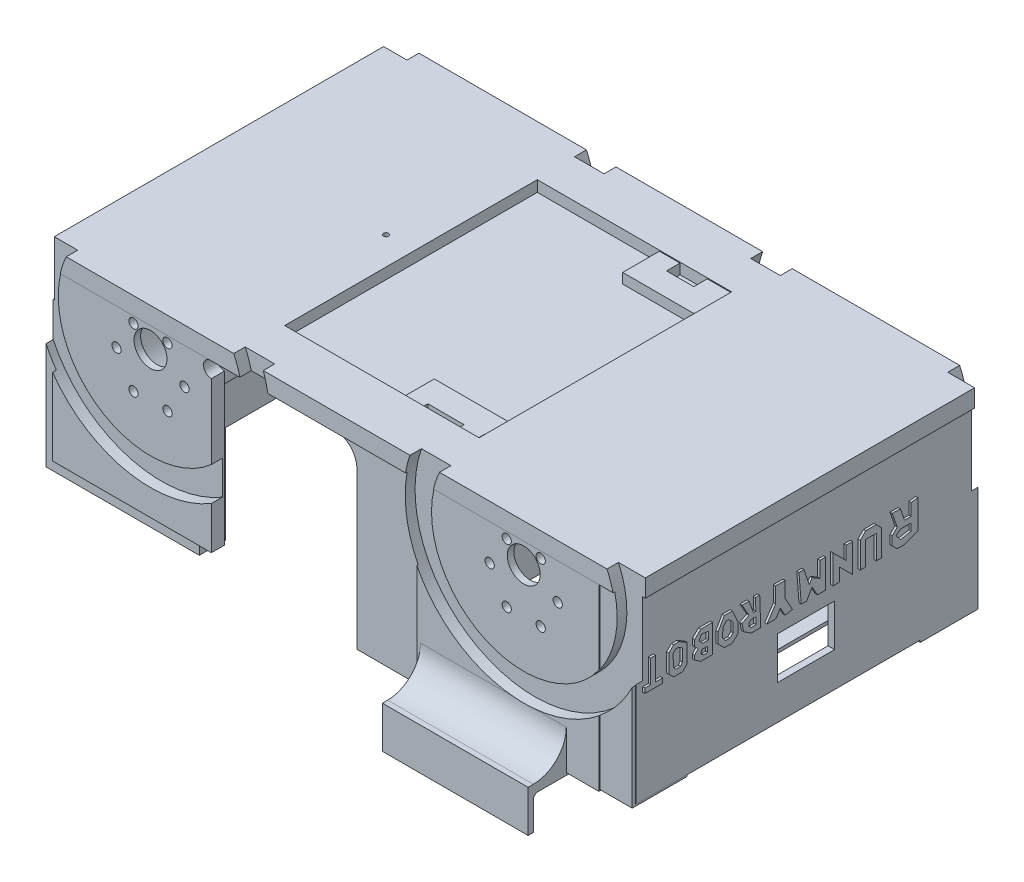
from build123d import *

# Parameters (mm, degrees)
MOTORHOLDERSSKETCH_R          = 23.41
MOTORHOLDERS_DEPTH            = 80
MOTORHOLDERS_DEPTH_BACK       = 80
MOTORHOLDERS_2_DEPTH          = 80
MOTORHOLDERS_2_DEPTH_BACK     = 80
SKETCH4_W                     = 262.774983374
SKETCH4_H                     = 153.112553215
CUT_EXTRUDE1_DEPTH            = 26
SKETCH6_W                     = 74.414236541
SKETCH6_H                     = 13.420779118
SKETCH6_W_2                   = 20.810206851
SKETCH6_H_2                   = 2.021058642
POWERBANKHOLDERS_DEPTH        = 30
POWERBANKHOLDERS_DEPTH_BACK   = 59
SKETCH6_W_3                   = 69.833389767
SKETCH6_H_3                   = 38.261259506
SKETCH6_W_4                   = 10.842850571
SKETCH6_H_4                   = 10.347679347
POWERBANKHOLDERS_2_DEPTH      = 30
POWERBANKHOLDERS_2_DEPTH_BACK = 59
SKETCH6_W_5                   = 55.674763771
SKETCH6_H_5                   = 37.111507406
SKETCH6_W_6                   = 12.844328805
SKETCH6_H_6                   = 18.336479725
SKETCH6_W_7                   = 12.407504742
SKETCH6_H_7                   = 16.443461188
POWERBANKHOLDERS_3_DEPTH      = 30
POWERBANKHOLDERS_3_DEPTH_BACK = 59
SKETCH6_W_8                   = 56.474336521
SKETCH6_H_8                   = 35.272094794
SKETCH6_W_9                   = 11.134493861
SKETCH6_H_9                   = 18.035399163
SKETCH6_W_10                  = 16.537391536
SKETCH6_H_10                  = 14.436538778
POWERBANKHOLDERS_4_DEPTH      = 30
POWERBANKHOLDERS_4_DEPTH_BACK = 59
SKETCH6_W_11                  = 28.150495439
SKETCH6_H_11                  = 24.933985152
SKETCH6_W_12                  = 10.177859407
SKETCH6_H_12                  = 9.83070569
POWERBANKHOLDERS_5_DEPTH      = 30
POWERBANKHOLDERS_5_DEPTH_BACK = 59
SKETCH6_W_13                  = 30.670744753
SKETCH6_H_13                  = 26.330219561
SKETCH6_W_14                  = 9.898416255
SKETCH6_H_14                  = 10.635603546
POWERBANKHOLDERS_6_DEPTH      = 30
POWERBANKHOLDERS_6_DEPTH_BACK = 59
SKETCH21_R                    = 156.395305675
SKETCH21_W                    = 88.537320887
SKETCH21_H                    = 115.069025425
BOTTOMPLATE_DEPTH             = 5
BOTTOMPLATE_DEPTH_BACK        = 3
SKETCH23_W                    = 72.331231332
SKETCH23_H                    = 81.163054316
SKETCH23_W_2                  = 82.936115801
SKETCH23_H_2                  = 87.063331284
MOTORMOUNTINGSUPPORT1_DEPTH   = 6
SKETCH24_W                    = 78.341994801
SKETCH24_H                    = 86.363062387
SKETCH24_W_2                  = 53.914675369
SKETCH24_H_2                  = 86.674739968
MOTORMOUNTINGSUPPOR2_DEPTH    = 6
SKETCH17_R                    = 2.1
SKETCH17_R_2                  = 7.5
MOTORHOLES1_DEPTH             = 31.5
SKETCH19_R                    = 2.1
SKETCH19_R_2                  = 7.5
CUT_EXTRUDE4_DEPTH            = 30
BOLTHOLESSKETCH3_R            = 2.1
BOLTHOLESSKETCH3_R_2          = 7.5
MOTORHOLES3_DEPTH             = 31.5
BOLTHOLESSKETCH4_R            = 2.1
BOLTHOLESSKETCH4_R_2          = 7.5
MOTORHOLES4_DEPTH             = 15
SKETCH29_W                    = 154.635205036
SKETCH29_H                    = 84.131588093
SKETCH29_W_2                  = 26
SKETCH29_H_2                  = 19.212652328
BOSS_EXTRUDE8_DEPTH           = 3
SKETCH27_W                    = 226.46009322
SKETCH27_H                    = 129.985211715
BOSS_EXTRUDE6_DEPTH           = 3
SKETCH28_W                    = 66.387115975
SKETCH28_H                    = 194.116469537
CELLPHONEPLATE_DEPTH          = 1.5
CELLPHONEPLATE_DEPTH_BACK     = 2.5
SKETCH40_W                    = 33.841577611
SKETCH40_H                    = 31.531825246
BOSS_EXTRUDE11_DEPTH          = 40
FILLET2_R                     = 15
FILLET3_R                     = 15
POWERBANKCUT_DEPTH            = 44.404272
MOTORHOLDEREXTRUDESKETCH_R    = 20.415
MOTORHOLDERCUT_DEPTH          = 77
MOTORHOLDERCUT_DEPTH_BACK     = 77
LABEL_DEPTH                   = 1
SKETCH32_W                    = 420.045569038
SKETCH32_H                    = 425.046527557
SKETCH32_W_2                  = 269.205670794
SKETCH32_H_2                  = 160.645125556
BASEDEFININGCUT_DEPTH         = 20
BASEDEFININGCUT_DEPTH_BACK    = 20
SKETCH36_R                    = 7.790164171
CUT_EXTRUDE6_DEPTH            = 40
SKETCH37_W                    = 55.340133611
SKETCH37_H                    = 29.7708905
CUT_EXTRUDE7_DEPTH            = 36
SKETCH38_R                    = 1.145182774
CUT_EXTRUDE8_DEPTH            = 10
SKETCH41_R                    = 54.5
SKETCH41_R_2                  = 42
SPACEFORWHEEL1_DEPTH          = 10
SPACEFORWHEEL1_DEPTH_BACK     = 5
SKETCH42_R                    = 54.5
SKETCH42_R_2                  = 42
CUT_EXTRUDE10_DEPTH           = 10
CUT_EXTRUDE10_DEPTH_BACK      = 5
SKETCH43_R                    = 54.5
SKETCH43_R_2                  = 42
CUT_EXTRUDE11_DEPTH           = 10
CUT_EXTRUDE11_DEPTH_BACK      = 5
SKETCH44_R                    = 54.5
SKETCH44_R_2                  = 42
CUT_EXTRUDE12_DEPTH           = 10
CUT_EXTRUDE12_DEPTH_BACK      = 5
SKETCH45_W                    = 114.137539603
SKETCH45_H                    = 89.690999312
BOSS_EXTRUDE12_DEPTH          = 2
FILLET4_R                     = 15
FILLET5_R                     = 15
SKETCH47_W                    = 66.387115975
SKETCH47_H                    = 3.279012993
SKETCH47_H_2                  = 2.432330743
BOSS_EXTRUDE14_DEPTH          = 15
FILLET6_R                     = 2
FILLET7_R                     = 2
FILLET8_R                     = 10
FILLET9_R                     = 10
FILLET10_R                    = 10
SKETCH49_R                    = 3.583077442
CUT_EXTRUDE13_DEPTH           = 6


with BuildPart() as part:
    # MotorHoldersSketch → MotorHolders (new body, two sides)
    with BuildSketch(Plane.XY) as motorholders_sk:
        Circle(MOTORHOLDERSSKETCH_R)
    extrude(amount=MOTORHOLDERS_DEPTH)
    extrude(motorholders_sk.sketch, amount=-MOTORHOLDERS_DEPTH_BACK)


with BuildPart() as body_2:
    # MotorHoldersSketch → MotorHolders 2 (new body, two sides)
    with BuildSketch(Plane.XY) as motorholders_2_sk:
        with Locations((170, 0)):
            Circle(MOTORHOLDERSSKETCH_R)
    extrude(amount=MOTORHOLDERS_2_DEPTH)
    extrude(motorholders_2_sk.sketch, amount=-MOTORHOLDERS_2_DEPTH_BACK)


with BuildPart() as cut_extrude1_tool:
    # Sketch4 → Cut-Extrude1 (new body)
    with BuildSketch(Plane(origin=(0, 0, 0), x_dir=(1, 0, 0), z_dir=(0, 1, 0))):
        with Locations((89.893628689, 0.176832173)):
            Rectangle(SKETCH4_W, SKETCH4_H)
    extrude(amount=-CUT_EXTRUDE1_DEPTH)


with BuildPart() as part_1:
    add(part.part)

    # Cut-Extrude1: cut by cut_extrude1_tool
    add(cut_extrude1_tool.part, mode=Mode.SUBTRACT)


with BuildPart() as body_2_1:
    add(body_2.part)

    # Cut-Extrude1: cut by cut_extrude1_tool
    add(cut_extrude1_tool.part, mode=Mode.SUBTRACT)


with BuildPart() as body_3:
    # Sketch6 → PowerBankHolders (new body, two sides)
    with BuildSketch(Plane(origin=(170, -34.829272125, 0), x_dir=(-1, 0, 0), z_dir=(0, -1, 0))) as powerbankholders_sk:
        with Locations((182.378728269, 72.238602394)):
            Rectangle(SKETCH6_W, SKETCH6_H)
        with Locations((203.359863582, 72.025840015)):
            Rectangle(SKETCH6_W_2, SKETCH6_H_2, mode=Mode.SUBTRACT)
    extrude(amount=POWERBANKHOLDERS_DEPTH)
    extrude(powerbankholders_sk.sketch, amount=-POWERBANKHOLDERS_DEPTH_BACK)



with BuildPart() as body_4:
    # Sketch6 → PowerBankHolders 2 (new body, two sides)
    with BuildSketch(Plane(origin=(170, -34.829272125, 0), x_dir=(-1, 0, 0), z_dir=(0, -1, 0))) as powerbankholders_2_sk:
        with Locations((184.398032618, -59.151522269)):
            Rectangle(SKETCH6_W_3, SKETCH6_H_3)
        with Locations((206.519672379, -65.314281269)):
            Rectangle(SKETCH6_W_4, SKETCH6_H_4, mode=Mode.SUBTRACT)
    extrude(amount=POWERBANKHOLDERS_2_DEPTH)
    extrude(powerbankholders_2_sk.sketch, amount=-POWERBANKHOLDERS_2_DEPTH_BACK)


with BuildPart() as body_5:
    # Sketch6 → PowerBankHolders 3 (new body, two sides)
    with BuildSketch(Plane(origin=(170, -34.829272125, 0), x_dir=(-1, 0, 0), z_dir=(0, -1, 0))) as powerbankholders_3_sk:
        with Locations((47.827743092, 59.306920349)):
            Rectangle(SKETCH6_W_5, SKETCH6_H_5)
        with Locations((34.93306737, 60.00949088)):
            Rectangle(SKETCH6_W_6, SKETCH6_H_6, mode=Mode.SUBTRACT)
        with Locations((60.073413265, 59.541495334)):
            Rectangle(SKETCH6_W_7, SKETCH6_H_7, mode=Mode.SUBTRACT)
    extrude(amount=POWERBANKHOLDERS_3_DEPTH)
    extrude(powerbankholders_3_sk.sketch, amount=-POWERBANKHOLDERS_3_DEPTH_BACK)


with BuildPart() as body_6:
    # Sketch6 → PowerBankHolders 4 (new body, two sides)
    with BuildSketch(Plane(origin=(170, -34.829272125, 0), x_dir=(-1, 0, 0), z_dir=(0, -1, 0))) as powerbankholders_4_sk:
        with Locations((48.322417758, -61.807610384)):
            Rectangle(SKETCH6_W_8, SKETCH6_H_8)
        with Locations((37.73953158, -63.792391966)):
            Rectangle(SKETCH6_W_9, SKETCH6_H_9, mode=Mode.SUBTRACT)
        with Locations((59.979410768, -62.645522509)):
            Rectangle(SKETCH6_W_10, SKETCH6_H_10, mode=Mode.SUBTRACT)
    extrude(amount=POWERBANKHOLDERS_4_DEPTH)
    extrude(powerbankholders_4_sk.sketch, amount=-POWERBANKHOLDERS_4_DEPTH_BACK)


with BuildPart() as body_7:
    # Sketch6 → PowerBankHolders 5 (new body, two sides)
    with BuildSketch(Plane(origin=(170, -34.829272125, 0), x_dir=(-1, 0, 0), z_dir=(0, -1, 0))) as powerbankholders_5_sk:
        with Locations((-34.775388772, -66.976665205)):
            Rectangle(SKETCH6_W_11, SKETCH6_H_11)
        with Locations((-36.725173705, -67.894738702)):
            Rectangle(SKETCH6_W_12, SKETCH6_H_12, mode=Mode.SUBTRACT)
    extrude(amount=POWERBANKHOLDERS_5_DEPTH)
    extrude(powerbankholders_5_sk.sketch, amount=-POWERBANKHOLDERS_5_DEPTH_BACK)


with BuildPart() as body_8:
    # Sketch6 → PowerBankHolders 6 (new body, two sides)
    with BuildSketch(Plane(origin=(170, -34.829272125, 0), x_dir=(-1, 0, 0), z_dir=(0, -1, 0))) as powerbankholders_6_sk:
        with Locations((-33.722690809, 64.697564271)):
            Rectangle(SKETCH6_W_13, SKETCH6_H_13)
        with Locations((-36.585452129, 63.859928969)):
            Rectangle(SKETCH6_W_14, SKETCH6_H_14, mode=Mode.SUBTRACT)
    extrude(amount=POWERBANKHOLDERS_6_DEPTH)
    extrude(powerbankholders_6_sk.sketch, amount=-POWERBANKHOLDERS_6_DEPTH_BACK)


with BuildPart() as body_3_1:
    add(body_3.part)

    add(body_4.part)  # BottomPlate merges body 4

    add(body_2_1.part)  # BottomPlate merges body 2

    add(part_1.part)  # BottomPlate merges part

    add(body_5.part)  # BottomPlate merges body 5

    add(body_6.part)  # BottomPlate merges body 6
    # Sketch21 → BottomPlate (add, two sides)
    with BuildSketch(Plane(origin=(0, 19.575, 0), x_dir=(1, 0, 0), z_dir=(0, 1, 0))) as bottomplate_sk:
        with Locations((85, 0)):
            Circle(SKETCH21_R)
        with Locations((82.978570093, -0.057259585)):
            Rectangle(SKETCH21_W, SKETCH21_H, mode=Mode.SUBTRACT)
    extrude(amount=BOTTOMPLATE_DEPTH)
    extrude(bottomplate_sk.sketch, amount=-BOTTOMPLATE_DEPTH_BACK)


    add(body_7.part)  # MotorMountingSupport1 merges body 7
    # Sketch23 → MotorMountingSupport1 (add)
    with BuildSketch(Plane.XY.offset(80)):
        with Locations((-8.424510745, -18.741332274)):
            Rectangle(SKETCH23_W, SKETCH23_H)
        with Locations((162.789906406, -21.691470758)):
            Rectangle(SKETCH23_W_2, SKETCH23_H_2)
    extrude(amount=-MOTORMOUNTINGSUPPORT1_DEPTH)


    add(body_8.part)  # MotorMountingSuppor2 merges body 8
    # Sketch24 → MotorMountingSuppor2 (add)
    with BuildSketch(Plane(origin=(0, 0, -80), x_dir=(-1, 0, 0), z_dir=(0, 0, -1))):
        with Locations((-163.019522912, -23.94412431)):
            Rectangle(SKETCH24_W, SKETCH24_H)
        with Locations((2.593149567, -20.814772641)):
            Rectangle(SKETCH24_W_2, SKETCH24_H_2)
    extrude(amount=-MOTORMOUNTINGSUPPOR2_DEPTH)

    # Sketch17 → MotorHoles1 (cut)
    with BuildSketch(Plane.XY.offset(80)):
        with Locations((185.5, 0)):
            Circle(SKETCH17_R)
        with Locations((177.75, -13.42)):
            Circle(SKETCH17_R)
        with Locations((162.25, -13.42)):
            Circle(SKETCH17_R)
        with Locations((154.5, 0)):
            Circle(SKETCH17_R)
        with Locations((162.25, 13.42)):
            Circle(SKETCH17_R)
        with Locations((177.75, 13.42)):
            Circle(SKETCH17_R)
        with Locations((170, 7)):
            Circle(SKETCH17_R_2)
    extrude(amount=-MOTORHOLES1_DEPTH, mode=Mode.SUBTRACT)

    # Sketch19 → Cut-Extrude4 (cut)
    with BuildSketch(Plane(origin=(0, 0, -80), x_dir=(-1, 0, 0), z_dir=(0, 0, -1))):
        with Locations((-185.5, 0)):
            Circle(SKETCH19_R)
        with Locations((-177.75, -13.42)):
            Circle(SKETCH19_R)
        with Locations((-162.25, -13.42)):
            Circle(SKETCH19_R)
        with Locations((-154.5, 0)):
            Circle(SKETCH19_R)
        with Locations((-162.25, 13.42)):
            Circle(SKETCH19_R)
        with Locations((-177.75, 13.42)):
            Circle(SKETCH19_R)
        with Locations((-170, 7)):
            Circle(SKETCH19_R_2)
    extrude(amount=-CUT_EXTRUDE4_DEPTH, mode=Mode.SUBTRACT)

    # BoltHolesSketch3 → MotorHoles3 (cut)
    with BuildSketch(Plane.XY.offset(80)):
        with Locations((7.75, -13.42)):
            Circle(BOLTHOLESSKETCH3_R)
        with Locations((15.5, 0)):
            Circle(BOLTHOLESSKETCH3_R)
        with Locations((7.75, 13.42)):
            Circle(BOLTHOLESSKETCH3_R)
        with Locations((-7.75, 13.42)):
            Circle(BOLTHOLESSKETCH3_R)
        with Locations((-15.5, 0)):
            Circle(BOLTHOLESSKETCH3_R)
        with Locations((-7.75, -13.42)):
            Circle(BOLTHOLESSKETCH3_R)
        with Locations((0, 7)):
            Circle(BOLTHOLESSKETCH3_R_2)
    extrude(amount=-MOTORHOLES3_DEPTH, mode=Mode.SUBTRACT)

    # BoltHolesSketch4 → MotorHoles4 (cut)
    with BuildSketch(Plane(origin=(0, 0, -80), x_dir=(-1, 0, 0), z_dir=(0, 0, -1))):
        with Locations((-15.5, 0)):
            Circle(BOLTHOLESSKETCH4_R)
        with Locations((-7.75, 13.42)):
            Circle(BOLTHOLESSKETCH4_R)
        with Locations((7.75, 13.42)):
            Circle(BOLTHOLESSKETCH4_R)
        with Locations((15.5, 0)):
            Circle(BOLTHOLESSKETCH4_R)
        with Locations((7.75, -13.42)):
            Circle(BOLTHOLESSKETCH4_R)
        with Locations((-7.75, -13.42)):
            Circle(BOLTHOLESSKETCH4_R)
        with Locations((0, 7)):
            Circle(BOLTHOLESSKETCH4_R_2)
    extrude(amount=-MOTORHOLES4_DEPTH, mode=Mode.SUBTRACT)

    # Sketch29 → Boss-Extrude8 (add)
    with BuildSketch(Plane(origin=(219.058063185, 0, 0), x_dir=(0, 0, -1), z_dir=(1, 0, 0))):
        with Locations((-0.622085312, -21.859578752)):
            Rectangle(SKETCH29_W, SKETCH29_H)
        with Locations((-0.45071267, -38.546737855)):
            Rectangle(SKETCH29_W_2, SKETCH29_H_2, mode=Mode.SUBTRACT)
    extrude(amount=-BOSS_EXTRUDE8_DEPTH)

    # Sketch27 → Boss-Extrude6 (add)
    with BuildSketch(Plane(origin=(0, 16.575, 0), x_dir=(-1, 0, 0), z_dir=(0, -1, 0))):
        with Locations((-81.596376522, -0.440920076)):
            Rectangle(SKETCH27_W, SKETCH27_H)
    extrude(amount=-BOSS_EXTRUDE6_DEPTH)

    # Sketch28 → CellPhonePlate (add, two sides)
    with BuildSketch(Plane(origin=(0, -64.829272125, 0), x_dir=(-1, 0, 0), z_dir=(0, -1, 0))) as cellphoneplate_sk:
        with Locations((-156.196154729, -0.339067123)):
            Rectangle(SKETCH28_W, SKETCH28_H)
    extrude(amount=CELLPHONEPLATE_DEPTH)
    extrude(cellphoneplate_sk.sketch, amount=-CELLPHONEPLATE_DEPTH_BACK)

    # Sketch40 → Boss-Extrude11 (add)
    with BuildSketch(Plane.XZ.offset(-16.575)):
        with Locations((-32.665057733, -49.762300212)):
            Rectangle(SKETCH40_W, SKETCH40_H)
    extrude(amount=BOSS_EXTRUDE11_DEPTH)

    # Fillet2
    fillet2_edges = [body_3_1.edges().sort_by_distance(p)[0] for p in [
        (-33.058778866, 16.575, -33.996387589),
    ]]
    fillet(fillet2_edges, radius=FILLET2_R)

    # Fillet3
    fillet3_edges = [body_3_1.edges().sort_by_distance(p)[0] for p in [
        (-32.665057733, -23.425, -65.528212835),
    ]]
    fillet(fillet3_edges, radius=FILLET3_R)

    # Sketch11 → PowerBankCut (cut)
    with BuildSketch(Plane(origin=(0, -20.425, 0), x_dir=(1, 0, 0), z_dir=(0, 1, 0))):
        Polygon((-34.216190018, -64.758061011), (-34.216190018, 73.342459946), (204.216190018, 63.61100878), (204.216190018, -72.195407715), align=None)
    extrude(amount=-POWERBANKCUT_DEPTH, mode=Mode.SUBTRACT)

    # MotorHolderExtrudeSketch → MotorHolderCut (cut, two sides)
    with BuildSketch(Plane.XY) as motorholdercut_sk:
        with Locations((170, 0)):
            Circle(MOTORHOLDEREXTRUDESKETCH_R)
        Circle(MOTORHOLDEREXTRUDESKETCH_R)
    extrude(amount=MOTORHOLDERCUT_DEPTH, mode=Mode.SUBTRACT)
    extrude(motorholdercut_sk.sketch, amount=-MOTORHOLDERCUT_DEPTH_BACK, mode=Mode.SUBTRACT)

    # Sketch31 → Label (add)
    with BuildSketch(Plane(origin=(219.058063185, 0, 0), x_dir=(0, 0, -1), z_dir=(1, 0, 0))):
        Polygon((49.44174371, -6.192727454), (49.44174371, -19.373871934), (42.934240846, -21.634082149), (40.061775134, -21.634082149), (37.786330287, -19.358637302), (37.786330287, -15.381348839), (40.061775134, -13.105903993), (37.786330287, -6.554538213), (41.49800799, -6.554538213), (43.400438848, -12.031937694), (46.389004897, -12.031937694), (46.389004897, -6.554538213), align=None)
        Polygon((46.389004897, -17.885685432), (46.389004897, -14.591500132), (41.49800799, -14.591500132), (39.506689527, -16.25408163), (41.565563867, -18.720050661), align=None, mode=Mode.SUBTRACT)
        Polygon((33.019279212, -21.634082149), (33.019279212, -9.830221103), (30.540166598, -7.351108489), (25.720297263, -7.351108489), (23.241184649, -9.830221103), (23.241184649, -21.634082149), (25.720297263, -21.634082149), (25.720297263, -10.745357897), (30.540166598, -10.745357897), (30.540166598, -21.634082149), align=None)
        Polygon((19.722613698, -8.590664796), (19.722613698, -21.634082149), (13.820683175, -15.732151626), (13.820683175, -21.634082149), (10.7708131, -21.634082149), (10.7708131, -8.590664796), (16.771648437, -14.591500132), (16.771648437, -8.590664796), align=None)
        Polygon((7.38910922, -8.590664796), (7.38910922, -21.634082149), (3.728231084, -21.634082149), (1.320922213, -17.369993071), (-1.251934103, -21.634082149), (-3.655389162, -21.634082149), (-4.691643117, -8.590664796), (-2.453661633, -8.590664796), (0.034494055, -15.754458747), (1.320922213, -13.622414208), (4.854437776, -15.754458747), (4.854437776, -8.590664796), align=None)
        Polygon((-7.682306608, -21.634082149), (-10.987514091, -15.754458747), (-10.987514091, -8.590664796), (-15.310206688, -8.590664796), (-15.310206688, -15.754458747), (-19.269516545, -21.634082149), (-15.310206688, -21.634082149), (-13.148860389, -18.424456549), (-10.987514091, -22.269268816), align=None)
        Polygon((-22.571010896, -8.590664796), (-22.098919416, -21.634082149), (-26.491509787, -21.634082149), (-29.911637517, -19.358637302), (-30.635996911, -15.754458747), (-27.413487689, -14.105212159), (-30.635996911, -8.590664796), (-27.413487689, -8.590664796), (-25.398720895, -14.105212159), (-24.295214602, -14.105212159), (-24.494807297, -8.590664796), align=None)
        Polygon((-24.295214602, -19.358637302), (-24.295214602, -16.25408163), (-26.491509787, -16.25408163), (-27.413487689, -17.176059532), (-27.413487689, -18.424456549), (-26.333852082, -19.504092156), align=None, mode=Mode.SUBTRACT)
        Polygon((-35.009913233, -8.590664796), (-38.639456152, -8.590664796), (-41.524071596, -13.622414208), (-41.524071596, -18.424456549), (-38.639456152, -21.309071994), (-35.009913233, -21.309071994), (-32.497839278, -18.796998039), (-32.497839278, -14.105212159), align=None)
        Polygon((-36.111415057, -18.796998039), (-34.718122355, -17.403705336), (-34.718122355, -13.105903993), (-36.662704643, -11.161321704), (-37.865915536, -11.161321704), (-39.310718257, -13.105903993), (-39.515454652, -16.854377093), (-38.250007481, -18.720050661), align=None, mode=Mode.SUBTRACT)
        Polygon((-44.059291997, -21.309071994), (-44.059291997, -8.590664796), (-49.449943726, -8.590664796), (-52.226947095, -11.367668165), (-52.226947095, -14.105212159), (-50.577700506, -15.754458747), (-52.226947095, -17.403705336), (-52.226947095, -19.358637302), (-49.449943726, -21.309071994), align=None)
        Polygon((-46.243610757, -16.854377093), (-48.903166093, -16.854377093), (-49.449943726, -18.424456549), (-48.083567545, -19.358637302), (-46.243610757, -19.358637302), align=None, mode=Mode.SUBTRACT)
        Polygon((-45.920604156, -14.591500132), (-45.920604156, -11.161321704), (-49.210466936, -10.745357897), (-50.175617033, -12.876410918), (-48.58914421, -14.591500132), align=None, mode=Mode.SUBTRACT)
        Polygon((-57.797660681, -21.309071994), (-55.60105832, -19.112469633), (-55.60105832, -10.745357897), (-59.263729006, -8.590664796), (-61.781771114, -8.590664796), (-63.936464214, -10.745357897), (-63.936464214, -19.112469633), (-61.781771114, -21.267162733), align=None)
        Polygon((-58.567152612, -18.720050661), (-57.797660681, -17.403705336), (-57.797660681, -11.763595566), (-59.657270857, -10.745357897), (-60.814447819, -10.745357897), (-62.101027616, -12.031937694), (-61.781771114, -17.403705336), (-60.814447819, -18.720050661), align=None, mode=Mode.SUBTRACT)
        Polygon((-66.791767957, -21.267162733), (-74.870531799, -21.267162733), (-74.870531799, -19.112469633), (-72.266477292, -19.112469633), (-72.266477292, -8.590664796), (-69.997684236, -8.590664796), (-69.997684236, -19.112469633), (-66.791767957, -19.112469633), align=None)
    extrude(amount=LABEL_DEPTH)

    # Sketch32 → BaseDefiningCut (cut, two sides)
    with BuildSketch(Plane(origin=(0, 19.575, 0), x_dir=(1, 0, 0), z_dir=(0, 1, 0))) as basedefiningcut_sk:
        with Locations((73.53385004, -6.203492346)):
            Rectangle(SKETCH32_W, SKETCH32_H)
        with Locations((85.789158114, 0.107563087)):
            Rectangle(SKETCH32_W_2, SKETCH32_H_2, mode=Mode.SUBTRACT)
    extrude(amount=BASEDEFININGCUT_DEPTH, mode=Mode.SUBTRACT)
    extrude(basedefiningcut_sk.sketch, amount=-BASEDEFININGCUT_DEPTH_BACK, mode=Mode.SUBTRACT)

    # Sketch36 → Cut-Extrude6 (cut)
    with BuildSketch(Plane.ZY.offset(49.314727501)):
        with Locations((49.382152022, -38.368879339)):
            Circle(SKETCH36_R)
    extrude(amount=-CUT_EXTRUDE6_DEPTH, mode=Mode.SUBTRACT)

    # Sketch37 → Cut-Extrude7 (cut)
    with BuildSketch(Plane.XZ.offset(20.425)):
        with Locations((116.745978541, -50.558354808)):
            Rectangle(SKETCH37_W, SKETCH37_H)
    extrude(amount=-CUT_EXTRUDE7_DEPTH, mode=Mode.SUBTRACT)

    # Sketch38 → Cut-Extrude8 (cut)
    with BuildSketch(Plane.XZ.offset(-16.575)):
        with Locations((25.99644574, -1.316498015)):
            Circle(SKETCH38_R)
    extrude(amount=-CUT_EXTRUDE8_DEPTH, mode=Mode.SUBTRACT)

    # Sketch41 → SpaceForWheel1 (cut, two sides)
    with BuildSketch(Plane.XY.offset(80)) as spaceforwheel1_sk:
        with Locations((0, 7)):
            Circle(SKETCH41_R)
        with Locations((0, 7)):
            Circle(SKETCH41_R_2, mode=Mode.SUBTRACT)
    extrude(amount=SPACEFORWHEEL1_DEPTH, mode=Mode.SUBTRACT)
    extrude(spaceforwheel1_sk.sketch, amount=-SPACEFORWHEEL1_DEPTH_BACK, mode=Mode.SUBTRACT)

    # Sketch42 → Cut-Extrude10 (cut, two sides)
    with BuildSketch(Plane.XY.offset(80)) as cut_extrude10_sk:
        with Locations((170, 7)):
            Circle(SKETCH42_R)
        with Locations((170, 7)):
            Circle(SKETCH42_R_2, mode=Mode.SUBTRACT)
    extrude(amount=CUT_EXTRUDE10_DEPTH, mode=Mode.SUBTRACT)
    extrude(cut_extrude10_sk.sketch, amount=-CUT_EXTRUDE10_DEPTH_BACK, mode=Mode.SUBTRACT)

    # Sketch43 → Cut-Extrude11 (cut, two sides)
    with BuildSketch(Plane(origin=(0, 0, -80), x_dir=(-1, 0, 0), z_dir=(0, 0, -1))) as cut_extrude11_sk:
        with Locations((-170, 7)):
            Circle(SKETCH43_R)
        with Locations((-170, 7)):
            Circle(SKETCH43_R_2, mode=Mode.SUBTRACT)
    extrude(amount=CUT_EXTRUDE11_DEPTH, mode=Mode.SUBTRACT)
    extrude(cut_extrude11_sk.sketch, amount=-CUT_EXTRUDE11_DEPTH_BACK, mode=Mode.SUBTRACT)

    # Sketch44 → Cut-Extrude12 (cut, two sides)
    with BuildSketch(Plane(origin=(0, 0, -80), x_dir=(-1, 0, 0), z_dir=(0, 0, -1))) as cut_extrude12_sk:
        with Locations((0, 7)):
            Circle(SKETCH44_R)
        with Locations((0, 7)):
            Circle(SKETCH44_R_2, mode=Mode.SUBTRACT)
    extrude(amount=CUT_EXTRUDE12_DEPTH, mode=Mode.SUBTRACT)
    extrude(cut_extrude12_sk.sketch, amount=-CUT_EXTRUDE12_DEPTH_BACK, mode=Mode.SUBTRACT)

    # Sketch45 → Boss-Extrude12 (add)
    with BuildSketch(Plane.ZY.offset(48.813677283)):
        with Locations((-15.037538426, -20.270499656)):
            Rectangle(SKETCH45_W, SKETCH45_H)
    extrude(amount=-BOSS_EXTRUDE12_DEPTH)

    # Fillet4
    fillet4_edges = [body_3_1.edges().sort_by_distance(p)[0] for p in [
        (156.196154729, -62.329272125, 80),
    ]]
    fillet(fillet4_edges, radius=FILLET4_R)

    # Fillet5
    fillet5_edges = [body_3_1.edges().sort_by_distance(p)[0] for p in [
        (156.619119114, -62.329272125, -80),
    ]]
    fillet(fillet5_edges, radius=FILLET5_R)

    # Sketch47 → Boss-Extrude14 (add)
    with BuildSketch(Plane.XZ.offset(66.329272125)):
        with Locations((156.196154729, -95.079661149)):
            Rectangle(SKETCH47_W, SKETCH47_H)
        with Locations((156.196154729, 96.181136521)):
            Rectangle(SKETCH47_W, SKETCH47_H_2)
    extrude(amount=BOSS_EXTRUDE14_DEPTH)

    # Fillet6
    fillet6_edges = [body_3_1.edges().sort_by_distance(p)[0] for p in [
        (156.196154729, -66.329272125, -93.440154652),
    ]]
    fillet(fillet6_edges, radius=FILLET6_R)

    # Fillet7
    fillet7_edges = [body_3_1.edges().sort_by_distance(p)[0] for p in [
        (156.196154729, -66.329272125, 94.964971149),
    ]]
    fillet(fillet7_edges, radius=FILLET7_R)

    # Fillet8
    fillet8_edges = [body_3_1.edges().sort_by_distance(p)[0] for p in [
        (24.828390002, 16.575, -72.238602394),
    ]]
    fillet(fillet8_edges, radius=FILLET8_R)

    # Fillet9
    fillet9_edges = [body_3_1.edges().sort_by_distance(p)[0] for p in [
        (94.334875023, 16.575, -59.306920349),
    ]]
    fillet(fillet9_edges, radius=FILLET9_R)

    # Fillet10
    fillet10_edges = [body_3_1.edges().sort_by_distance(p)[0] for p in [
        (93.440413982, 16.575, 61.807610384),
    ]]
    fillet(fillet10_edges, radius=FILLET10_R)

    # Sketch49 → Cut-Extrude13 (cut)
    with BuildSketch(Plane.XY.offset(80)):
        with Locations((27.741104921, 12.952971073)):
            Circle(SKETCH49_R)
    extrude(amount=-CUT_EXTRUDE13_DEPTH, mode=Mode.SUBTRACT)


solid = body_3_1.part
